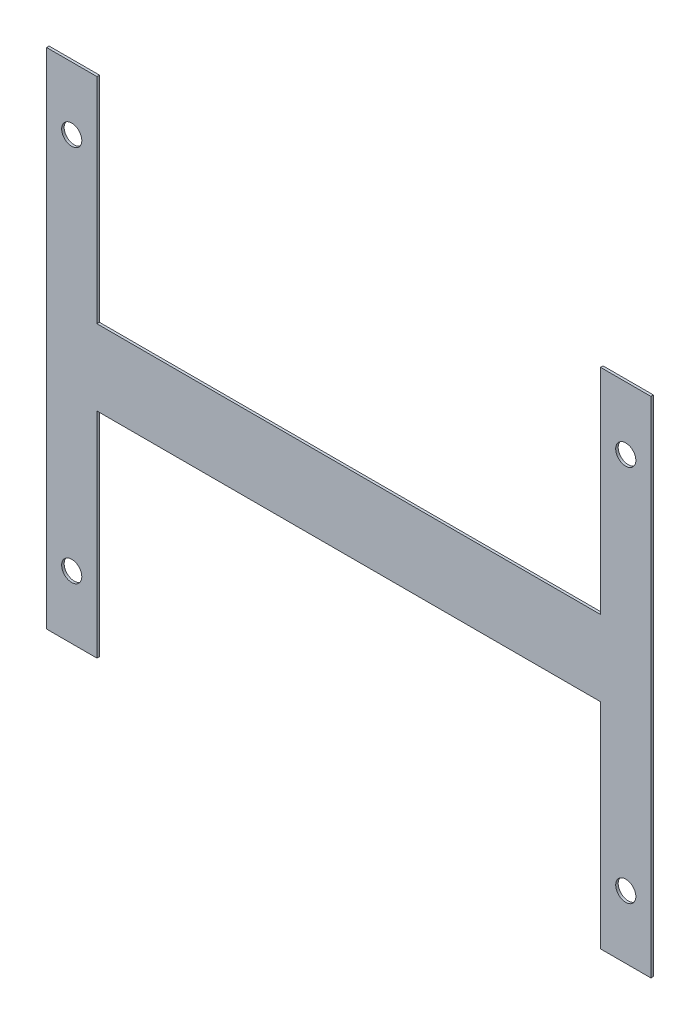
from build123d import *

# Parameters (mm, degrees)
SKETCH1_W           = 200
SKETCH1_H           = 30
SKETCH1_W_2         = 20
SKETCH1_H_2         = 200
SKETCH1_R           = 4
BOSS_EXTRUDE1_DEPTH = 1


with BuildPart() as part:
    # Sketch1 → Boss-Extrude1 (new body)
    with BuildSketch(Plane.XY):
        with Locations((120, 100)):
            Rectangle(SKETCH1_W, SKETCH1_H)
        with Locations((10, 100)):
            Rectangle(SKETCH1_W_2, SKETCH1_H_2)
        with Locations((10, 175)):
            Circle(SKETCH1_R, mode=Mode.SUBTRACT)
        with Locations((10, 25)):
            Circle(SKETCH1_R, mode=Mode.SUBTRACT)
        Polygon((220, 200), (220, 115), (220, 85), (220, 0), (240, 0), (240, 200), align=None)
        with Locations((230, 25)):
            Circle(SKETCH1_R, mode=Mode.SUBTRACT)
        with Locations((230, 175)):
            Circle(SKETCH1_R, mode=Mode.SUBTRACT)
    extrude(amount=BOSS_EXTRUDE1_DEPTH)


solid = part.part
